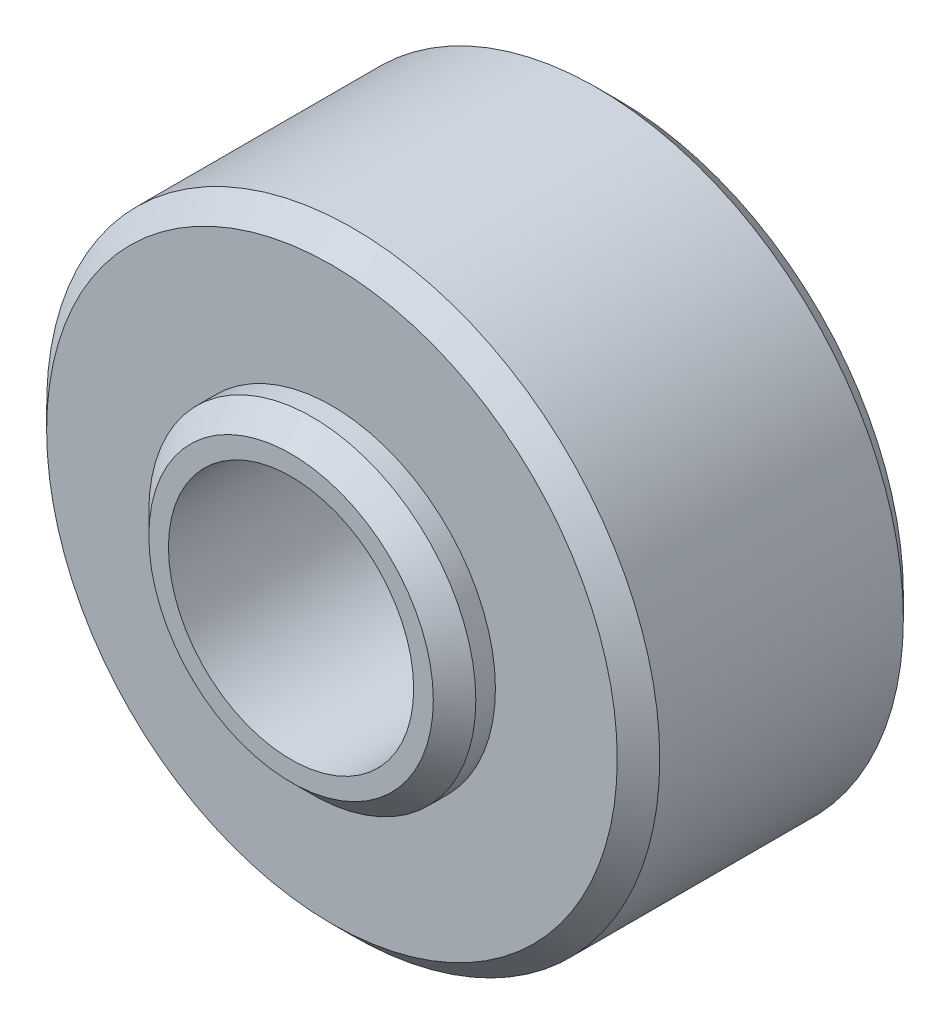
from build123d import *

# Parameters (mm, degrees)
SKETCH1_R           = 7.5
BOSS_EXTRUDE1_DEPTH = 7
SKETCH2_R           = 4
BOSS_EXTRUDE2_DEPTH = 1
SKETCH3_R           = 3
CUT_EXTRUDE1_DEPTH  = 9
CHAMFER1_SIZE       = 0.52


with BuildPart() as part:
    # Sketch1 → Boss-Extrude1 (new body)
    with BuildSketch(Plane.XY):
        Circle(SKETCH1_R)
    extrude(amount=BOSS_EXTRUDE1_DEPTH)

    # Sketch2 → Boss-Extrude2 (add)
    with BuildSketch(Plane.XY.offset(7)):
        Circle(SKETCH2_R)
    extrude(amount=BOSS_EXTRUDE2_DEPTH)

    # Sketch3 → Cut-Extrude1 (cut, through all)
    with BuildSketch(Plane.XY.offset(8)):
        Circle(SKETCH3_R)
    extrude(amount=-CUT_EXTRUDE1_DEPTH, mode=Mode.SUBTRACT)

    # Chamfer1
    chamfer1_edges = [part.edges().sort_by_distance(p)[0] for p in [
        (-3, 0, 0),
        (-7.5, 0, 0),
        (-7.5, 0, 7),
        (-4, 0, 8),
    ]]
    chamfer(chamfer1_edges, length=CHAMFER1_SIZE)


solid = part.part
